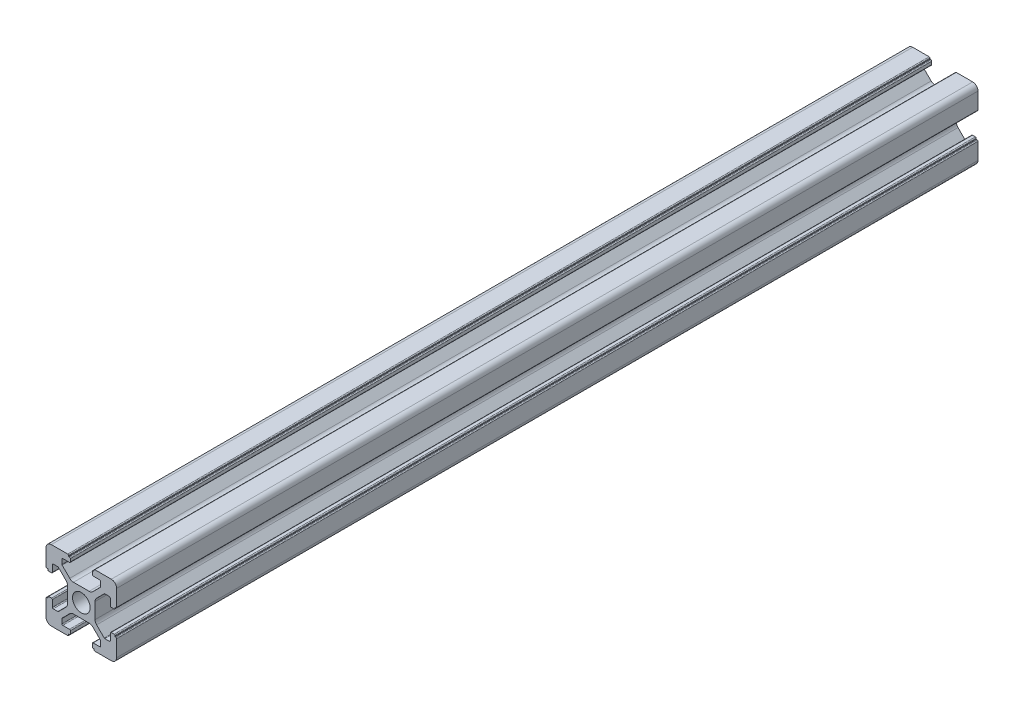
from build123d import *

# Parameters (mm, degrees)
SKETCH_1_R      = 2.5
EXTRUDE_1_DEPTH = 244


with BuildPart() as part:
    # 草图1 → 凸台-拉伸1 (new body)
    with BuildSketch(Plane.XY):
        with BuildLine():
            Line((-8.502261885, -10.002261885), (-3.85, -10.002261885))
            ThreePointArc((-3.85, -10.002261885), (-3.673223305, -9.929038581), (-3.6, -9.752261885))
            Line((-3.6, -9.752261885), (-3.6, -9.502261885))
            Line((-3.6, -9.502261885), (-3.35, -9.502261885))
            ThreePointArc((-3.35, -9.502261885), (-3.173223305, -9.429038581), (-3.1, -9.252261885))
            Line((-3.1, -9.252261885), (-3.1, -8.45))
            ThreePointArc((-3.1, -8.45), (-3.173223305, -8.273223305), (-3.35, -8.2))
            Line((-3.35, -8.2), (-5.25, -8.2))
            ThreePointArc((-5.25, -8.2), (-5.426776695, -8.126776695), (-5.5, -7.95))
            Line((-5.5, -7.95), (-5.5, -6.664213562))
            ThreePointArc((-5.5, -6.664213562), (-5.480969883, -6.568542704), (-5.426776695, -6.487436867))
            Line((-5.426776695, -6.487436867), (-3.278679656, -4.339339828))
            ThreePointArc((-3.278679656, -4.339339828), (-2.792044633, -4.014180701), (-2.218019485, -3.9))
            Line((-2.218019485, -3.9), (2.218019485, -3.9))
            ThreePointArc((2.218019485, -3.9), (2.792044633, -4.014180701), (3.278679656, -4.339339828))
            Line((3.278679656, -4.339339828), (5.426776695, -6.487436867))
            ThreePointArc((5.426776695, -6.487436867), (5.480969883, -6.568542704), (5.5, -6.664213562))
            Line((5.5, -6.664213562), (5.5, -7.95))
            ThreePointArc((5.5, -7.95), (5.426776695, -8.126776695), (5.25, -8.2))
            Line((5.25, -8.2), (3.35, -8.2))
            ThreePointArc((3.35, -8.2), (3.173223305, -8.273223305), (3.1, -8.45))
            Line((3.1, -8.45), (3.1, -9.252261885))
            ThreePointArc((3.1, -9.252261885), (3.173223305, -9.429038581), (3.35, -9.502261885))
            Line((3.35, -9.502261885), (3.6, -9.502261885))
            Line((3.6, -9.502261885), (3.6, -9.752261885))
            ThreePointArc((3.6, -9.752261885), (3.673223305, -9.929038581), (3.85, -10.002261885))
            Line((3.85, -10.002261885), (8.502261885, -10.002261885))
            ThreePointArc((8.502261885, -10.002261885), (9.562922057, -9.562922057), (10.002261885, -8.502261885))
            Line((10.002261885, -8.502261885), (10.002261885, -3.85))
            ThreePointArc((10.002261885, -3.85), (9.929038581, -3.673223305), (9.752261885, -3.6))
            Line((9.752261885, -3.6), (9.502261885, -3.6))
            Line((9.502261885, -3.6), (9.502261885, -3.35))
            ThreePointArc((9.502261885, -3.35), (9.429038581, -3.173223305), (9.252261885, -3.1))
            Line((9.252261885, -3.1), (8.45, -3.1))
            ThreePointArc((8.45, -3.1), (8.273223305, -3.173223305), (8.2, -3.35))
            Line((8.2, -3.35), (8.2, -5.25))
            ThreePointArc((8.2, -5.25), (8.126776695, -5.426776695), (7.95, -5.5))
            Line((7.95, -5.5), (6.664213562, -5.5))
            ThreePointArc((6.664213562, -5.5), (6.568542704, -5.480969883), (6.487436867, -5.426776695))
            Line((6.487436867, -5.426776695), (4.339339828, -3.278679656))
            ThreePointArc((4.339339828, -3.278679656), (4.014180701, -2.792044633), (3.9, -2.218019485))
            Line((3.9, -2.218019485), (3.9, 2.218019485))
            ThreePointArc((3.9, 2.218019485), (4.014180701, 2.792044633), (4.339339828, 3.278679656))
            Line((4.339339828, 3.278679656), (6.487436867, 5.426776695))
            ThreePointArc((6.487436867, 5.426776695), (6.568542704, 5.480969883), (6.664213562, 5.5))
            Line((6.664213562, 5.5), (7.95, 5.5))
            ThreePointArc((7.95, 5.5), (8.126776695, 5.426776695), (8.2, 5.25))
            Line((8.2, 5.25), (8.2, 3.35))
            ThreePointArc((8.2, 3.35), (8.273223305, 3.173223305), (8.45, 3.1))
            Line((8.45, 3.1), (9.252261885, 3.1))
            ThreePointArc((9.252261885, 3.1), (9.429038581, 3.173223305), (9.502261885, 3.35))
            Line((9.502261885, 3.35), (9.502261885, 3.6))
            Line((9.502261885, 3.6), (9.752261885, 3.6))
            ThreePointArc((9.752261885, 3.6), (9.929038581, 3.673223305), (10.002261885, 3.85))
            Line((10.002261885, 3.85), (10.002261885, 8.502261885))
            ThreePointArc((10.002261885, 8.502261885), (9.562922057, 9.562922057), (8.502261885, 10.002261885))
            Line((8.502261885, 10.002261885), (3.85, 10.002261885))
            ThreePointArc((3.85, 10.002261885), (3.673223305, 9.929038581), (3.6, 9.752261885))
            Line((3.6, 9.752261885), (3.6, 9.502261885))
            Line((3.6, 9.502261885), (3.35, 9.502261885))
            ThreePointArc((3.35, 9.502261885), (3.173223305, 9.429038581), (3.1, 9.252261885))
            Line((3.1, 9.252261885), (3.1, 8.45))
            ThreePointArc((3.1, 8.45), (3.173223305, 8.273223305), (3.35, 8.2))
            Line((3.35, 8.2), (5.25, 8.2))
            ThreePointArc((5.25, 8.2), (5.426776695, 8.126776695), (5.5, 7.95))
            Line((5.5, 7.95), (5.5, 6.664213562))
            ThreePointArc((5.5, 6.664213562), (5.480969883, 6.568542704), (5.426776695, 6.487436867))
            Line((5.426776695, 6.487436867), (3.278679656, 4.339339828))
            ThreePointArc((3.278679656, 4.339339828), (2.792044633, 4.014180701), (2.218019485, 3.9))
            Line((2.218019485, 3.9), (-2.218019485, 3.9))
            ThreePointArc((-2.218019485, 3.9), (-2.792044633, 4.014180701), (-3.278679656, 4.339339828))
            Line((-3.278679656, 4.339339828), (-5.426776695, 6.487436867))
            ThreePointArc((-5.426776695, 6.487436867), (-5.480969883, 6.568542704), (-5.5, 6.664213562))
            Line((-5.5, 6.664213562), (-5.5, 7.95))
            ThreePointArc((-5.5, 7.95), (-5.426776695, 8.126776695), (-5.25, 8.2))
            Line((-5.25, 8.2), (-3.35, 8.2))
            ThreePointArc((-3.35, 8.2), (-3.173223305, 8.273223305), (-3.1, 8.45))
            Line((-3.1, 8.45), (-3.1, 9.252261885))
            ThreePointArc((-3.1, 9.252261885), (-3.173223305, 9.429038581), (-3.35, 9.502261885))
            Line((-3.35, 9.502261885), (-3.6, 9.502261885))
            Line((-3.6, 9.502261885), (-3.6, 9.752261885))
            ThreePointArc((-3.6, 9.752261885), (-3.673223305, 9.929038581), (-3.85, 10.002261885))
            Line((-3.85, 10.002261885), (-8.502261885, 10.002261885))
            ThreePointArc((-8.502261885, 10.002261885), (-9.562922057, 9.562922057), (-10.002261885, 8.502261885))
            Line((-10.002261885, 8.502261885), (-10.002261885, 3.85))
            ThreePointArc((-10.002261885, 3.85), (-9.929038581, 3.673223305), (-9.752261885, 3.6))
            Line((-9.752261885, 3.6), (-9.502261885, 3.6))
            Line((-9.502261885, 3.6), (-9.502261885, 3.35))
            ThreePointArc((-9.502261885, 3.35), (-9.429038581, 3.173223305), (-9.252261885, 3.1))
            Line((-9.252261885, 3.1), (-8.45, 3.1))
            ThreePointArc((-8.45, 3.1), (-8.273223305, 3.173223305), (-8.2, 3.35))
            Line((-8.2, 3.35), (-8.2, 5.25))
            ThreePointArc((-8.2, 5.25), (-8.126776695, 5.426776695), (-7.95, 5.5))
            Line((-7.95, 5.5), (-6.664213562, 5.5))
            ThreePointArc((-6.664213562, 5.5), (-6.568542704, 5.480969883), (-6.487436867, 5.426776695))
            Line((-6.487436867, 5.426776695), (-4.339339828, 3.278679656))
            ThreePointArc((-4.339339828, 3.278679656), (-4.014180701, 2.792044633), (-3.9, 2.218019485))
            Line((-3.9, 2.218019485), (-3.9, -2.218019485))
            ThreePointArc((-3.9, -2.218019485), (-4.014180701, -2.792044633), (-4.339339828, -3.278679656))
            Line((-4.339339828, -3.278679656), (-6.487436867, -5.426776695))
            ThreePointArc((-6.487436867, -5.426776695), (-6.568542704, -5.480969883), (-6.664213562, -5.5))
            Line((-6.664213562, -5.5), (-7.95, -5.5))
            ThreePointArc((-7.95, -5.5), (-8.126776695, -5.426776695), (-8.2, -5.25))
            Line((-8.2, -5.25), (-8.2, -3.35))
            ThreePointArc((-8.2, -3.35), (-8.273223305, -3.173223305), (-8.45, -3.1))
            Line((-8.45, -3.1), (-9.252261885, -3.1))
            ThreePointArc((-9.252261885, -3.1), (-9.429038581, -3.173223305), (-9.502261885, -3.35))
            Line((-9.502261885, -3.35), (-9.502261885, -3.6))
            Line((-9.502261885, -3.6), (-9.752261885, -3.6))
            ThreePointArc((-9.752261885, -3.6), (-9.929038581, -3.673223305), (-10.002261885, -3.85))
            Line((-10.002261885, -3.85), (-10.002261885, -8.502261885))
            ThreePointArc((-10.002261885, -8.502261885), (-9.562922057, -9.562922057), (-8.502261885, -10.002261885))
        make_face()
        Circle(SKETCH_1_R, mode=Mode.SUBTRACT)
    extrude(amount=EXTRUDE_1_DEPTH)


solid = part.part
